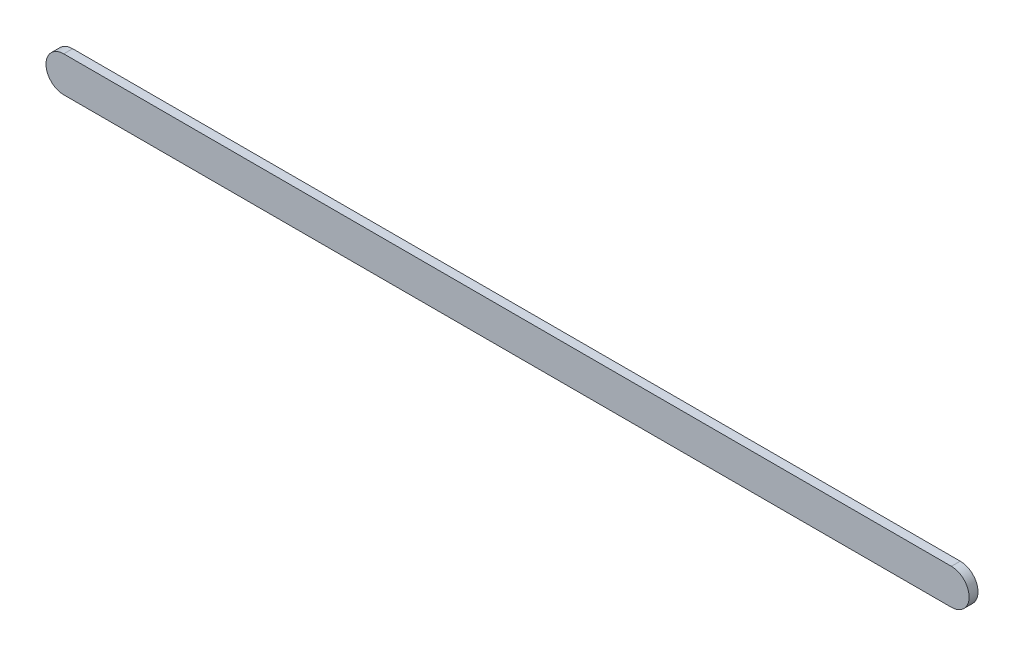
from build123d import *

# Parameters (mm, degrees)
BOSS_EXTRUDE1_DEPTH = 2.5


with BuildPart() as part:
    # Sketch2 → Boss-Extrude1 (new body)
    with BuildSketch(Plane.XY):
        with BuildLine():
            Line((-75.937752546, 5), (174.062247454, 5))
            ThreePointArc((174.062247454, 5), (179.062247454, 0), (174.062247454, -5))
            Line((174.062247454, -5), (-75.937752546, -5))
            ThreePointArc((-75.937752546, -5), (-80.937752546, 0), (-75.937752546, 5))
        make_face()
    extrude(amount=BOSS_EXTRUDE1_DEPTH)


solid = part.part
